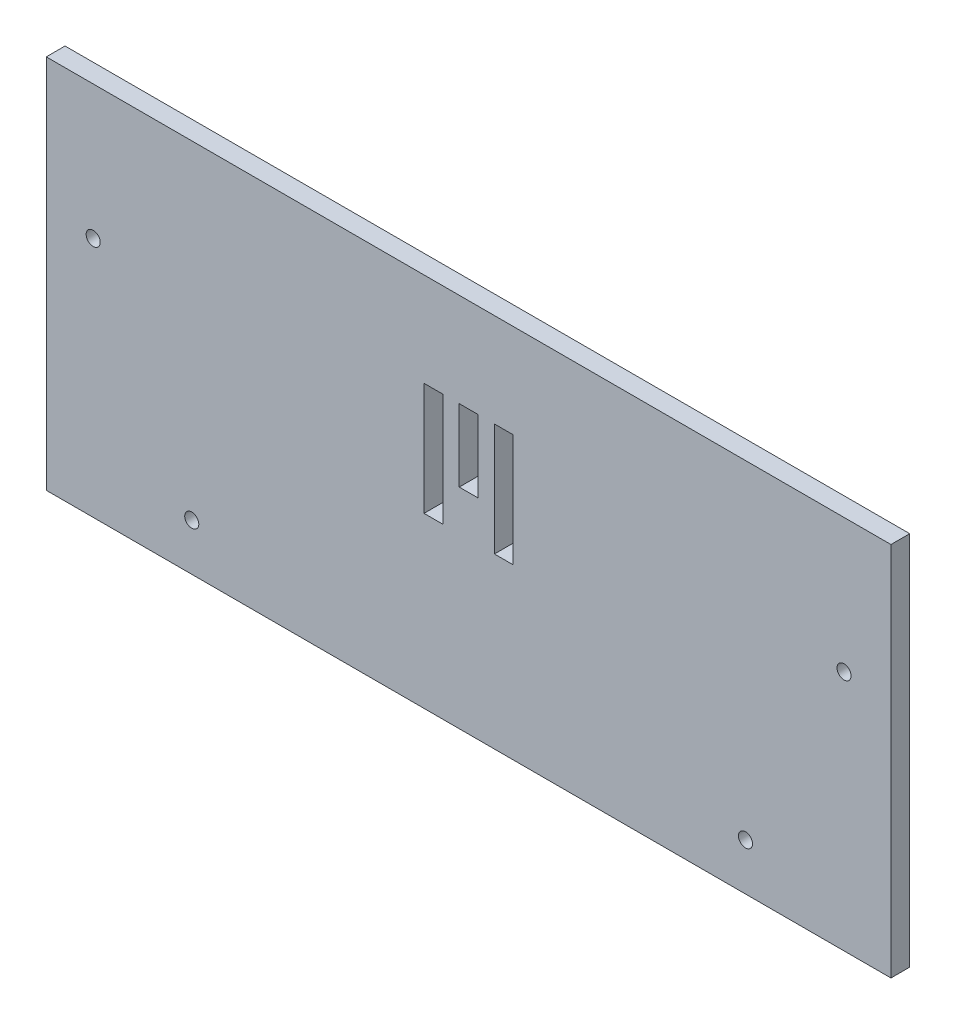
from build123d import *

# Parameters (mm, degrees)
SKETCH1_W           = 180
SKETCH1_H           = 80
SKETCH1_R           = 1.5
BOSS_EXTRUDE1_DEPTH = 4
SKETCH2_W           = 4
SKETCH2_H           = 24
SKETCH2_H_2         = 15.4
CUT_EXTRUDE1_DEPTH  = 4


with BuildPart() as part:
    # Sketch1 → Boss-Extrude1 (new body)
    with BuildSketch(Plane.XY):
        with Locations((2.700642055, -21.117125984)):
            Rectangle(SKETCH1_W, SKETCH1_H)
        with Locations((-77.299357945, -9.617125984)):
            Circle(SKETCH1_R, mode=Mode.SUBTRACT)
        with Locations((82.700642055, -9.617125984)):
            Circle(SKETCH1_R, mode=Mode.SUBTRACT)
        with Locations((61.700642055, -51.117125984)):
            Circle(SKETCH1_R, mode=Mode.SUBTRACT)
        with Locations((-56.299357945, -51.117125984)):
            Circle(SKETCH1_R, mode=Mode.SUBTRACT)
    extrude(amount=BOSS_EXTRUDE1_DEPTH)

    # Sketch2 → Cut-Extrude1 (cut)
    with BuildSketch(Plane.XY.offset(4)):
        with Locations((-4.799357945, -13.117125984)):
            Rectangle(SKETCH2_W, SKETCH2_H)
        with Locations((2.700642055, -8.817125984)):
            Rectangle(SKETCH2_W, SKETCH2_H_2)
        with Locations((10.200642055, -13.117125984)):
            Rectangle(SKETCH2_W, SKETCH2_H)
    extrude(amount=-CUT_EXTRUDE1_DEPTH, mode=Mode.SUBTRACT)


solid = part.part
